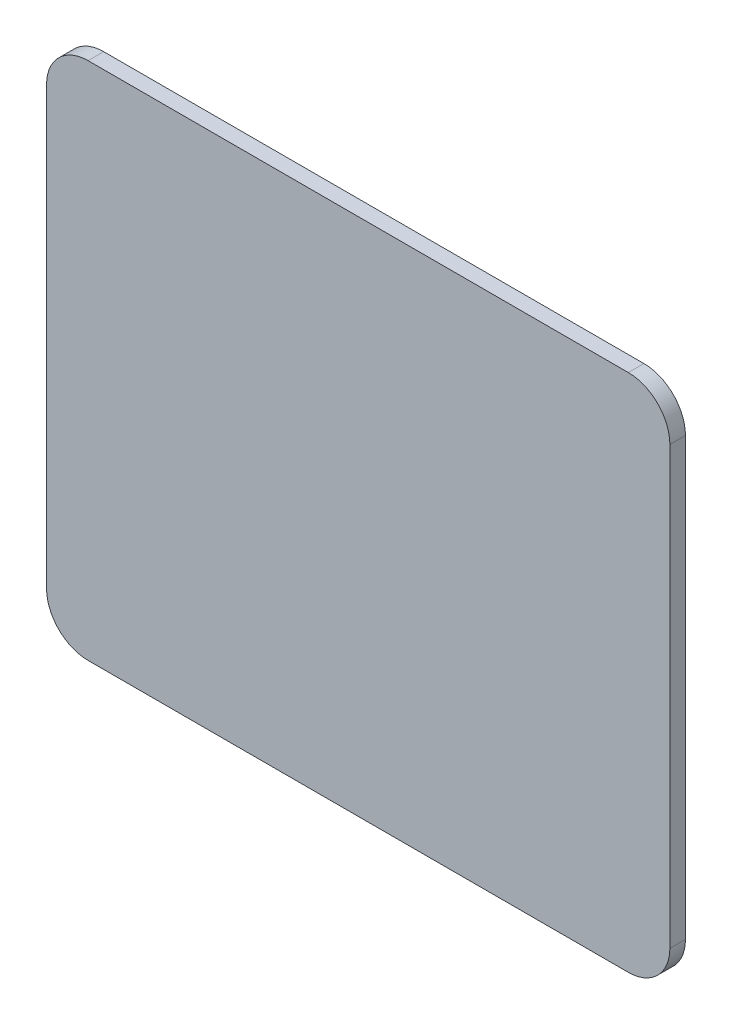
from build123d import *

# Parameters (mm, degrees)
BOSS_EXTRUDE1_DEPTH = 3


with BuildPart() as part:
    # Sketch1 → Boss-Extrude1 (new body)
    with BuildSketch(Plane.XY):
        with BuildLine():
            Line((-72.122052126, 155), (-72.122052126, 71))
            ThreePointArc((-72.122052126, 71), (-69.778906375, 65.343145751), (-64.122052126, 63))
            Line((-64.122052126, 63), (39.877947874, 63))
            ThreePointArc((39.877947874, 63), (45.534802123, 65.343145751), (47.877947874, 71))
            Line((47.877947874, 71), (47.877947874, 155))
            ThreePointArc((47.877947874, 155), (45.534802123, 160.65685425), (39.877947874, 163))
            Line((39.877947874, 163), (-64.122052126, 163))
            ThreePointArc((-64.122052126, 163), (-69.778906375, 160.65685425), (-72.122052126, 155))
        make_face()
    extrude(amount=-BOSS_EXTRUDE1_DEPTH)


solid = part.part
